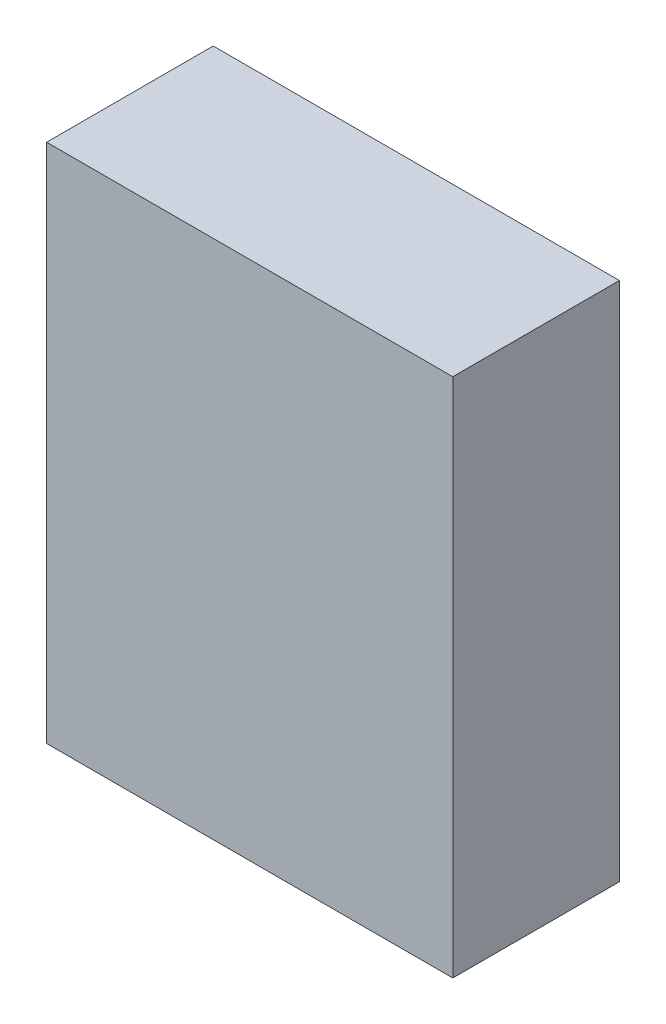
from build123d import *

# Parameters (mm, degrees)
SKETCH1_W           = 99.06
SKETCH1_H           = 127
BOSS_EXTRUDE1_DEPTH = 40.64


with BuildPart() as part:
    # Sketch1 → Boss-Extrude1 (new body)
    with BuildSketch(Plane.XY):
        with Locations((49.53, 63.5)):
            Rectangle(SKETCH1_W, SKETCH1_H)
    extrude(amount=BOSS_EXTRUDE1_DEPTH)


solid = part.part
